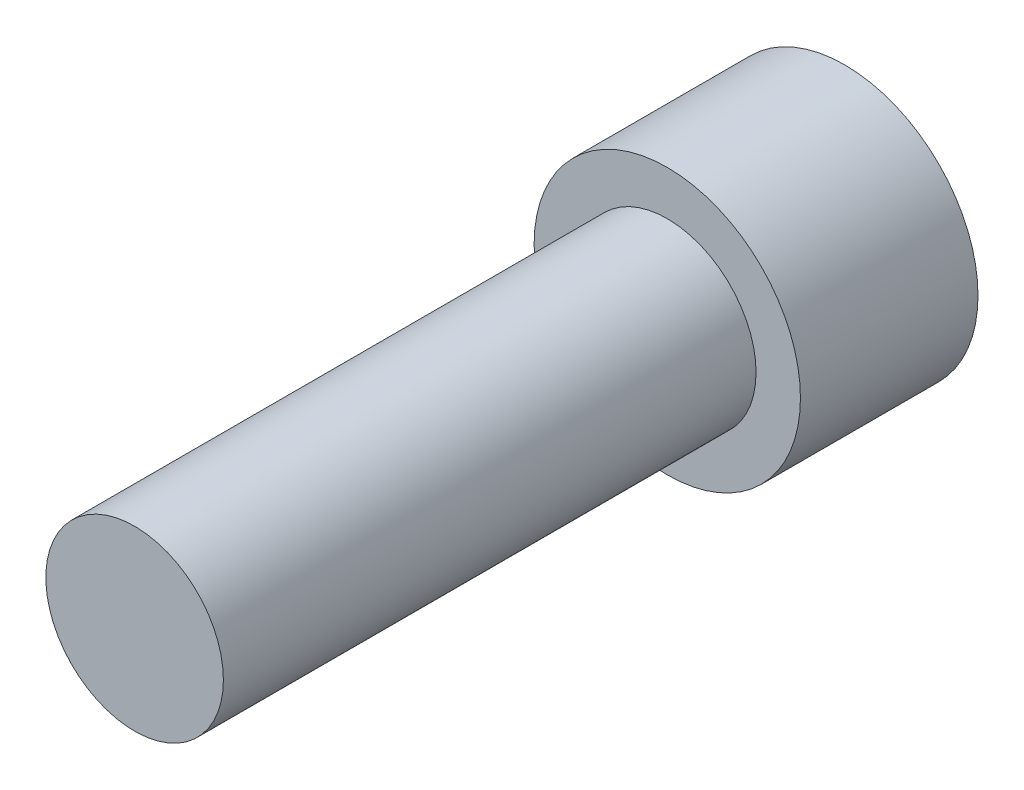
from build123d import *

# Parameters (mm, degrees)
CROQUIS1_R              = 0.75
SALIENTE_EXTRUIR1_DEPTH = 1
CROQUIS2_R              = 0.5
SALIENTE_EXTRUIR2_DEPTH = 3
CORTAR_EXTRUIR1_DEPTH   = 0.75


with BuildPart() as part:
    # Croquis1 → Saliente-Extruir1 (new body)
    with BuildSketch(Plane.XY):
        Circle(CROQUIS1_R)
    extrude(amount=SALIENTE_EXTRUIR1_DEPTH)

    # Croquis2 → Saliente-Extruir2 (add)
    with BuildSketch(Plane.XY.offset(1)):
        Circle(CROQUIS2_R)
    extrude(amount=SALIENTE_EXTRUIR2_DEPTH)

    # Croquis3 → Cortar-Extruir1 (cut)
    with BuildSketch(Plane(origin=(0, 0, 0), x_dir=(-1, 0, 0), z_dir=(0, 0, -1))):
        Polygon((0.577350269, 0), (0.288675135, 0.5), (-0.288675135, 0.5), (-0.577350269, 0), (-0.288675135, -0.5), (0.288675135, -0.5), align=None)
    extrude(amount=-CORTAR_EXTRUIR1_DEPTH, mode=Mode.SUBTRACT)


solid = part.part
